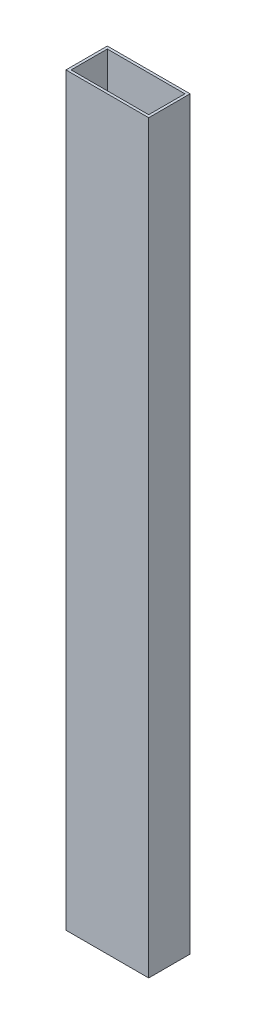
from build123d import *

# Parameters (mm, degrees)
SKETCH1_W           = 50.8
SKETCH1_H           = 25.4
SKETCH1_W_2         = 47.625
SKETCH1_H_2         = 22.225
BOSS_EXTRUDE1_DEPTH = 457.2


with BuildPart() as part:
    # Sketch1 → Boss-Extrude1 (new body)
    with BuildSketch(Plane(origin=(0, 228.6, 0), x_dir=(1, 0, 0), z_dir=(0, 1, 0))):
        with Locations((17.907513613, -7.23255612)):
            Rectangle(SKETCH1_W, SKETCH1_H)
        with Locations((17.907513613, -7.23255612)):
            Rectangle(SKETCH1_W_2, SKETCH1_H_2, mode=Mode.SUBTRACT)
    extrude(amount=-BOSS_EXTRUDE1_DEPTH)


solid = part.part
